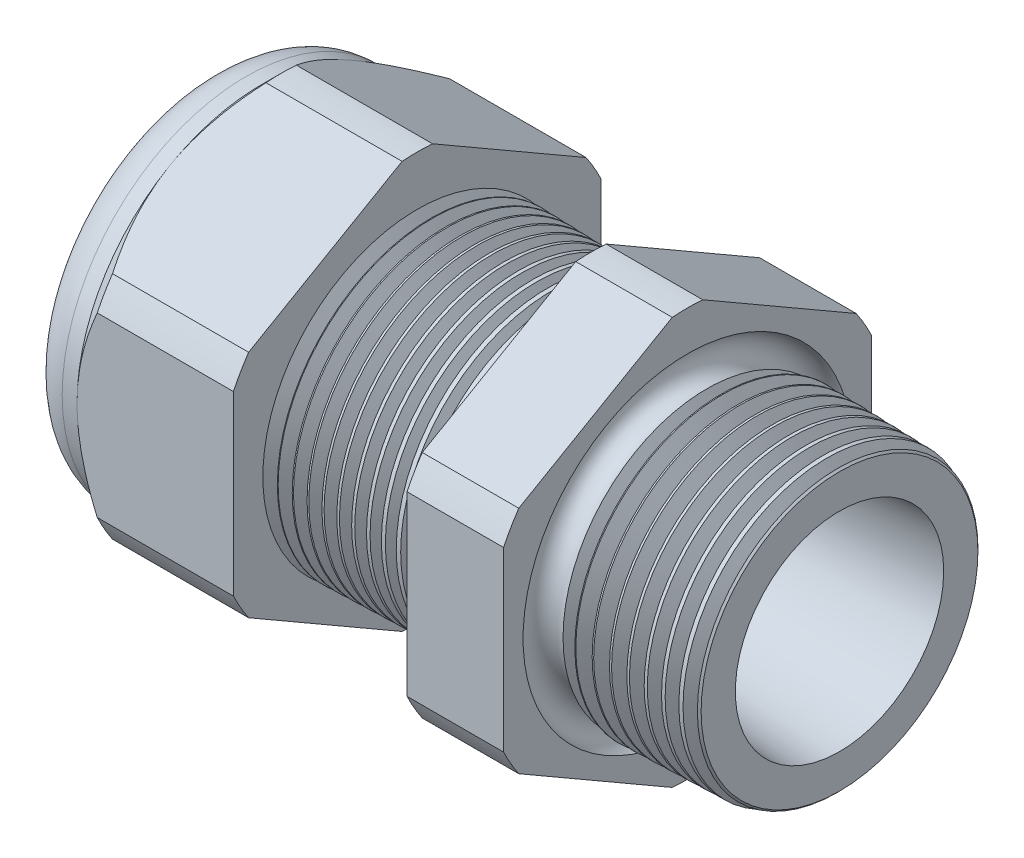
from build123d import *

# Parameters (mm, degrees)
SKETCH12_OUTSIDE_W = 52.712
SKETCH12_OUTSIDE_H = 52.712
CUT_EXTRUDE2_DEPTH = 30.966
FILLET4_R          = 2.032
SKETCH19_OUTSIDE_W = 33.73
SKETCH19_OUTSIDE_H = 35.826
SKETCH19_OUTSIDE_R = 9.525
CUT_EXTRUDE3_DEPTH = 1.999996
CUT_EXTRUDE3_DRAFT = -45
CHAMFER1_SIZE      = 0.260919487
CHAMFER1_SIZE2     = 0.254
SKETCH21_R         = 3.937
PLUG_DEPTH         = 3.81
SKETCH22_R         = 3.683
CUT_EXTRUDE4_DEPTH = 0.508
LPATTERN1_COUNT    = 12
LPATTERN1_PITCH    = 0.762
LPATTERN2_COUNT    = 9
LPATTERN2_PITCH    = 0.889
SKETCH32_R         = 0.889


with BuildPart() as part:
    # Sketch10 → Revolve2 (revolve)
    with BuildSketch(Plane.XY, mode=Mode.PRIVATE) as revolve2_sk:
        Polygon((-32.766, 3.937), (-21.866, 3.937), (0, 5.396418639), (0, 7.428418639), (-7.874, 7.634606585), (-7.874, 19.05), (-12.874, 19.05), (-12.874, 7.765536193), (-21.866, 8.001), (-21.866, 19.05), (-29.966, 19.05), (-29.966, 9.525), (-32.766, 9.525), align=None)
    revolve(revolve2_sk.sketch.rotate(Axis((0, 0, 0), (-1, 0, 0)), 90), axis=Axis((0, 0, 0), (-1, 0, 0)))  # turned: the seam where the file's is

    # Sketch12 outside → Cut-Extrude2 (cut, through all)
    with BuildSketch(Plane.ZY.offset(29.966)):
        Rectangle(SKETCH12_OUTSIDE_W, SKETCH12_OUTSIDE_H)
        with BuildLine():
            Line((-0.788451287, 10.543310065), (-8.736548713, 5.954473877))
            ThreePointArc((-8.736548713, 5.954473877), (-9.156270088, 5.286375), (-9.525, 4.588836188))
            Line((-9.525, 4.588836188), (-9.525, -4.588836188))
            ThreePointArc((-9.525, -4.588836188), (-9.156270088, -5.286375), (-8.736548713, -5.954473877))
            Line((-8.736548713, -5.954473877), (-0.788451287, -10.543310065))
            ThreePointArc((-0.788451287, -10.543310065), (0, -10.57275), (0.788451287, -10.543310065))
            Line((0.788451287, -10.543310065), (8.736548713, -5.954473877))
            ThreePointArc((8.736548713, -5.954473877), (9.156270088, -5.286375), (9.525, -4.588836188))
            Line((9.525, -4.588836188), (9.525, 4.588836188))
            ThreePointArc((9.525, 4.588836188), (9.156270088, 5.286375), (8.736548713, 5.954473877))
            Line((8.736548713, 5.954473877), (0.788451287, 10.543310065))
            ThreePointArc((0.788451287, 10.543310065), (0, 10.57275), (-0.788451287, 10.543310065))
        make_face(mode=Mode.SUBTRACT)
    extrude(amount=-CUT_EXTRUDE2_DEPTH, mode=Mode.SUBTRACT)

    # Fillet4
    fillet4_edges = [part.edges().sort_by_distance(p)[0] for p in [
        (-32.766, 0, 9.525),
    ]]
    fillet(fillet4_edges, radius=FILLET4_R)


with BuildPart() as cut_extrude3_tool:
    # Sketch19 outside → Cut-Extrude3 (with draft: the straight prism first)
    with BuildSketch(Plane.ZY.offset(29.966)):
        Rectangle(SKETCH19_OUTSIDE_W, SKETCH19_OUTSIDE_H)
        Circle(SKETCH19_OUTSIDE_R, mode=Mode.SUBTRACT)
    extrude(amount=-CUT_EXTRUDE3_DEPTH)
    # Cut-Extrude3: the draft: its side faces are tilted about the plane it starts from
    cut_extrude3_sides = [cut_extrude3_tool.faces().sort_by_distance(p)[0] for p in [
        (-28.966002, -17.913, 0),
        (-28.966002, 0, 16.865),
        (-28.966002, 17.913, 0),
        (-28.966002, 0, -16.865),
        (-28.966002, 0, -9.525),
    ]]
    draft(cut_extrude3_sides, Plane.ZY.offset(29.966), CUT_EXTRUDE3_DRAFT)


with BuildPart() as part_1:
    add(part.part)

    # Cut-Extrude3: cut by cut_extrude3_tool
    add(cut_extrude3_tool.part, mode=Mode.SUBTRACT)

    # Chamfer1
    chamfer1_edges = [part_1.edges().sort_by_distance(p)[0] for p in [
        (0, 0, 7.428418639),
    ]]
    chamfer1_side = [part_1.faces().sort_by_distance(p)[0] for p in [
        (0, 0, 5.606526047),
    ]]
    chamfer(chamfer1_edges, length=CHAMFER1_SIZE, length2=CHAMFER1_SIZE2, reference=chamfer1_side[0])

    # Sketch29 → Cut-Revolve1 (revolve, cut)
    with BuildSketch(Plane.XY, mode=Mode.PRIVATE) as cut_revolve1_sk:
        Polygon((-21.866, 8.001), (-21.133016419, 7.981806149), (-21.516130572, 7.356620673), align=None)
    cut_revolve1 = revolve(cut_revolve1_sk.sketch.rotate(Axis((0, 0, 0), (-1, 0, 0)), 90), axis=Axis((0, 0, 0), (-1, 0, 0)), mode=Mode.SUBTRACT)  # turned: the seam where the file's is

    # LPattern1: Cut-Revolve1 ×12
    with Locations(*[(i * LPATTERN1_PITCH, 0, 0) for i in range(1, LPATTERN1_COUNT)]):
        add(cut_revolve1, mode=Mode.SUBTRACT)

    # Sketch30 → Cut-Revolve2 (revolve, cut)
    with BuildSketch(Plane.XY, mode=Mode.PRIVATE) as cut_revolve2_sk:
        Polygon((-7.874, 7.634606585), (-6.994419703, 7.611573965), (-7.454156686, 6.861351393), align=None)
    cut_revolve2 = revolve(cut_revolve2_sk.sketch.rotate(Axis((0, 0, 0), (-1, 0, 0)), 270), axis=Axis((0, 0, 0), (-1, 0, 0)), mode=Mode.SUBTRACT)  # turned: the seam where the file's is

    # LPattern2: Cut-Revolve2 ×9
    with Locations(*[(i * LPATTERN2_PITCH, 0, 0) for i in range(1, LPATTERN2_COUNT)]):
        add(cut_revolve2, mode=Mode.SUBTRACT)

    # Sketch32 → Cut-Revolve3 (revolve, cut)
    with BuildSketch(Plane.XY, mode=Mode.PRIVATE) as cut_revolve3_sk:
        with Locations((-7.747, 7.634606585)):
            Circle(SKETCH32_R)
    revolve(cut_revolve3_sk.sketch.rotate(Axis((0, 0, 0), (-1, 0, 0)), 270), axis=Axis((0, 0, 0), (-1, 0, 0)), mode=Mode.SUBTRACT)  # turned: the seam where the file's is


with BuildPart() as body_2:
    # Sketch21 → plug (new body)
    with BuildSketch(Plane.ZY.offset(32.766)):
        Circle(SKETCH21_R)
    extrude(amount=-PLUG_DEPTH)

    # Sketch22 → Cut-Extrude4 (cut)
    with BuildSketch(Plane.ZY.offset(32.766)):
        Circle(SKETCH22_R)
    extrude(amount=-CUT_EXTRUDE4_DEPTH, mode=Mode.SUBTRACT)


solid = Compound([part_1.part, body_2.part])
